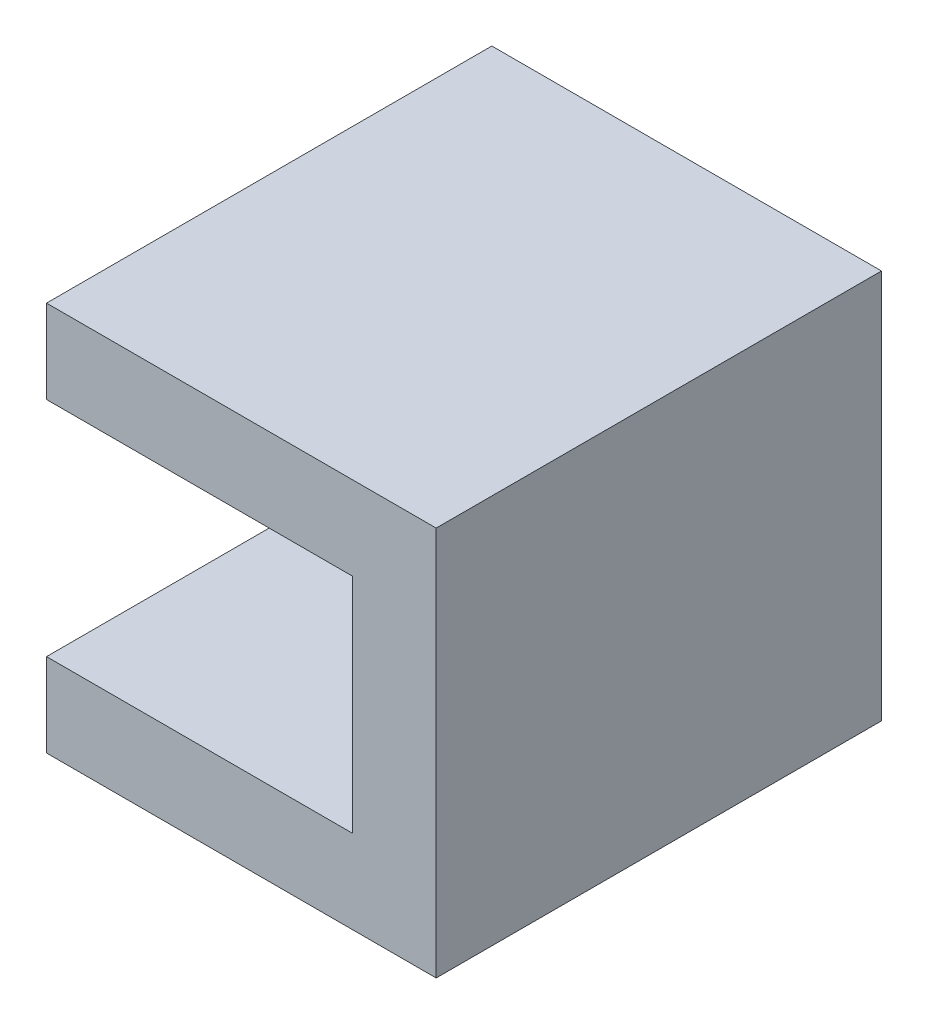
from build123d import *

# Parameters (mm, degrees)
BOSS_EXTRUDE1_DEPTH = 25.4
CUT_EXTRUDE1_DEPTH  = 6.35
CUT_EXTRUDE2_DEPTH  = 6.35


with BuildPart() as part:
    # Sketch1 → Boss-Extrude1 (new body, symmetric)
    with BuildSketch(Plane.XY):
        Polygon((-31.75, 22.225), (-31.75, 12.7), (-17.4625, 12.7), (-17.4625, 9.525), (-11.1125, 9.525), (-11.1125, 12.7), (3.175, 12.7), (3.175, 0), (0, 0), (0, -6.35), (3.175, -6.35), (3.175, -12.7), (-11.1125, -12.7), (-11.1125, -9.525), (-17.4625, -9.525), (-17.4625, -12.7), (-31.75, -12.7), (-31.75, -22.225), (12.7, -22.225), (12.7, 22.225), align=None)
    extrude(amount=BOSS_EXTRUDE1_DEPTH, both=True)

    # Sketch2 → Cut-Extrude1 (cut)
    with BuildSketch(Plane.ZY.offset(17.4625)):
        with BuildLine():
            ThreePointArc((3.175, 12.7), (2.245064024, 10.454935963), (-1.9e-08, 9.525))
            Line((-1.9e-08, 9.525), (25.4, 9.525))
            Line((25.4, 9.525), (25.4, 12.7))
            Line((25.4, 12.7), (3.175, 12.7))
        make_face()
        with BuildLine():
            Line((-3.175, 12.7), (-25.4, 12.7))
            Line((-25.4, 12.7), (-25.4, 9.525))
            Line((-25.4, 9.525), (-1.9e-08, 9.525))
            ThreePointArc((-1.9e-08, 9.525), (-2.245064037, 10.454935976), (-3.175, 12.7))
        make_face()
        with BuildLine():
            Line((-2e-09, -9.525), (-25.4, -9.525))
            Line((-25.4, -9.525), (-25.4, -12.7))
            Line((-25.4, -12.7), (-3.175, -12.7))
            ThreePointArc((-3.175, -12.7), (-2.245064031, -10.454935971), (-2e-09, -9.525))
        make_face()
        with BuildLine():
            Line((25.4, -9.525), (-2e-09, -9.525))
            ThreePointArc((-2e-09, -9.525), (2.245064029, -10.454935969), (3.175, -12.7))
            Line((3.175, -12.7), (25.4, -12.7))
            Line((25.4, -12.7), (25.4, -9.525))
        make_face()
    extrude(amount=-CUT_EXTRUDE1_DEPTH, mode=Mode.SUBTRACT)

    # Sketch3 → Cut-Extrude2 (cut)
    with BuildSketch(Plane(origin=(0, 0, 0), x_dir=(1, 0, 0), z_dir=(0, 1, 0))):
        with BuildLine():
            Line((0, 0), (0, -25.4))
            Line((0, -25.4), (3.175, -25.4))
            Line((3.175, -25.4), (3.175, -3.175))
            ThreePointArc((3.175, -3.175), (0.92993597, -2.24506403), (0, 0))
        make_face()
    cut_extrude2 = extrude(amount=-CUT_EXTRUDE2_DEPTH, mode=Mode.SUBTRACT)

    # Mirror1: Cut-Extrude2 across plane
    add(cut_extrude2.mirror(Plane.XY), mode=Mode.SUBTRACT)


solid = part.part
